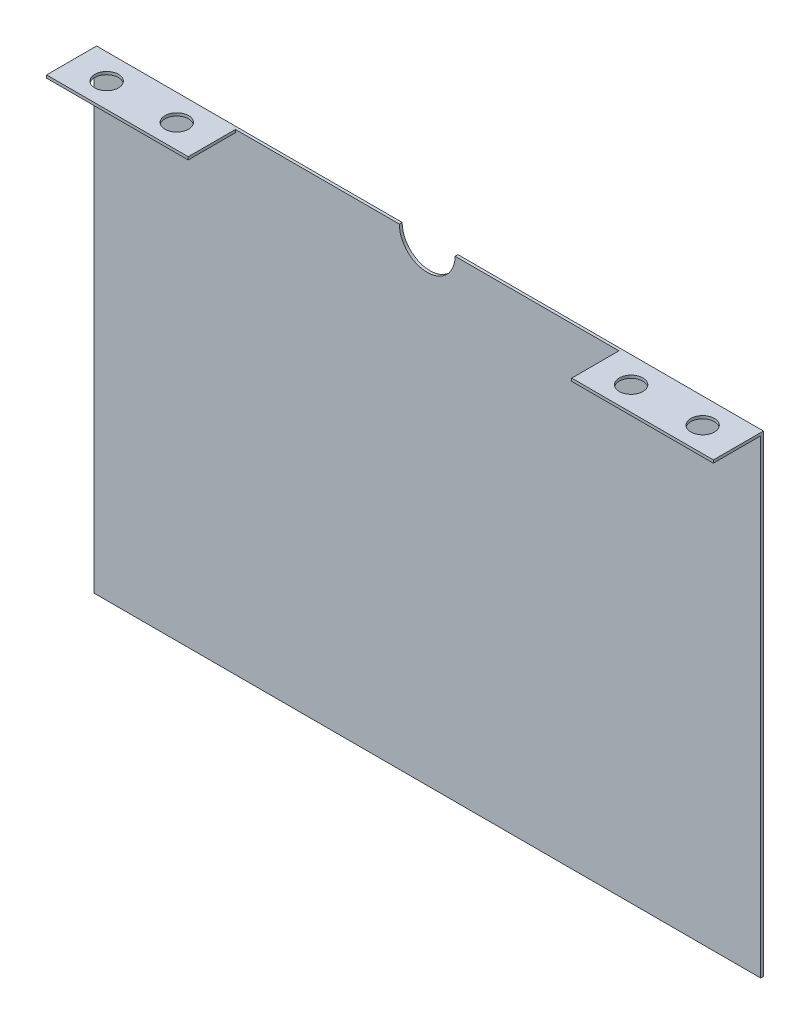
from build123d import *

# Parameters (mm, degrees)
BOTTOM_CENTER_CASING_DEPTH = 1.51892
SKETCH3_W                  = 76.2
SKETCH3_H                  = 1.51892
BOSS_EXTRUDE1_DEPTH        = 25.4
SKETCH4_R                  = 6.35
CUT_EXTRUDE1_DEPTH         = 25.4


with BuildPart() as part:
    # Sketch1 → Bottom Center Casing (new body)
    with BuildSketch(Plane.XY):
        with BuildLine():
            Line((-179.31892, 177.8), (-15, 177.8))
            ThreePointArc((-15, 177.8), (0, 162.8), (15, 177.8))
            Line((15, 177.8), (179.31892, 177.8))
            Line((179.31892, 177.8), (179.31892, -76.2))
            Line((179.31892, -76.2), (-179.31892, -76.2))
            Line((-179.31892, -76.2), (-179.31892, 177.8))
        make_face()
    extrude(amount=BOTTOM_CENTER_CASING_DEPTH)

    # Sketch3 → Boss-Extrude1 (add)
    with BuildSketch(Plane.XY.offset(1.51892)):
        with Locations((-141.21892, 177.04054)):
            Rectangle(SKETCH3_W, SKETCH3_H)
        with Locations((141.21892, 177.04054)):
            Rectangle(SKETCH3_W, SKETCH3_H)
    extrude(amount=BOSS_EXTRUDE1_DEPTH)

    # Sketch4 → Cut-Extrude1 (cut)
    with BuildSketch(Plane(origin=(0, 177.8, 0), x_dir=(1, 0, 0), z_dir=(0, 1, 0))):
        with Locations((-160.26892, -13.649325)):
            Circle(SKETCH4_R)
        with Locations((-122.16892, -14.029055)):
            Circle(SKETCH4_R)
        with Locations((122.16892, -14.029055)):
            Circle(SKETCH4_R)
        with Locations((160.26892, -13.649325)):
            Circle(SKETCH4_R)
    extrude(amount=-CUT_EXTRUDE1_DEPTH, mode=Mode.SUBTRACT)


solid = part.part
